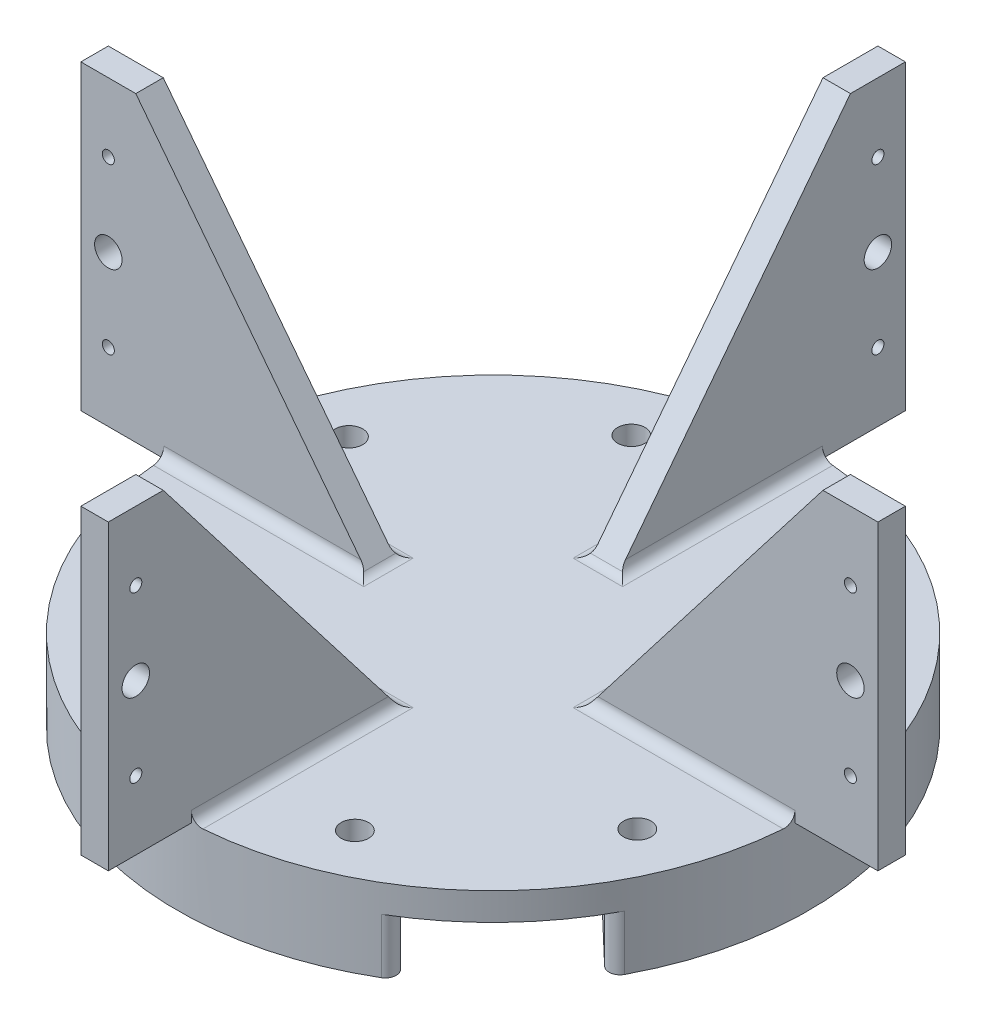
from build123d import *

# Parameters (mm, degrees)
SKETCH1_R           = 73.025
BOSS_EXTRUDE1_DEPTH = 19.05
CUT_EXTRUDE1_DEPTH  = 12.7
SKETCH3_R           = 3.175
CUT_EXTRUDE2_DEPTH  = 106.015254844
SKETCH6_R           = 1.397
SKETCH6_R_2         = 3.175
BOSS_EXTRUDE2_DEPTH = 3.175
FILLET1_R           = 7.62
FILLET2_R           = 2.54
CIRPATTERN1_COUNT   = 4
FILLET3_R           = 2.54


with BuildPart() as part:
    # Sketch1 → Boss-Extrude1 (new body)
    with BuildSketch(Plane(origin=(0, 0, 0), x_dir=(1, 0, 0), z_dir=(0, 1, 0))):
        Circle(SKETCH1_R)
    extrude(amount=-BOSS_EXTRUDE1_DEPTH)

    # Sketch2 → Cut-Extrude1 (cut)
    with BuildSketch(Plane.XZ.offset(19.05)):
        Polygon((47.265185668, 68.19146719), (-59.263487878, -33.567189015), (-36.236205762, -57.673893158), (70.292467784, 44.084763047), align=None)
    extrude(amount=-CUT_EXTRUDE1_DEPTH, mode=Mode.SUBTRACT)

    # Sketch3 → Cut-Extrude2 (cut, through all)
    with BuildSketch(Plane(origin=(0, 0, 0), x_dir=(1, 0, 0), z_dir=(0, 1, 0))):
        with Locations((-55.932366027, 22.598142748)):
            Circle(SKETCH3_R)
        with Locations((-23.570855326, 55.529455285)):
            Circle(SKETCH3_R)
        with Locations((22.598142748, 55.932366027)):
            Circle(SKETCH3_R)
        with Locations((55.529455285, 23.570855326)):
            Circle(SKETCH3_R)
        with Locations((55.932366027, -22.598142748)):
            Circle(SKETCH3_R)
        with Locations((23.570855326, -55.529455285)):
            Circle(SKETCH3_R)
        with Locations((-22.598142748, -55.932366027)):
            Circle(SKETCH3_R)
        with Locations((-55.529455285, -23.570855326)):
            Circle(SKETCH3_R)
    extrude(amount=-CUT_EXTRUDE2_DEPTH, mode=Mode.SUBTRACT)

    # Sketch6 → Boss-Extrude2 (add, symmetric)
    with BuildSketch(Plane.XY):
        Polygon((-25.460668916, 0), (-92.135668916, 0), (-92.135668916, 69.85), (-79.435668916, 69.85), align=None)
        with Locations((-85.785668916, 53.975)):
            Circle(SKETCH6_R, mode=Mode.SUBTRACT)
        with Locations((-85.785668916, 34.925)):
            Circle(SKETCH6_R_2, mode=Mode.SUBTRACT)
        with Locations((-85.785668916, 15.875)):
            Circle(SKETCH6_R, mode=Mode.SUBTRACT)
    boss_extrude2 = extrude(amount=BOSS_EXTRUDE2_DEPTH, both=True)

    # Fillet1
    fillet1_edges = [part.edges().sort_by_distance(p)[0] for p in [
        (-36.236205762, -12.7, -57.673893158),
        (-59.263487878, -12.7, -33.567189015),
    ]]
    fillet(fillet1_edges, radius=FILLET1_R)

    # Fillet2
    fillet2_edges = [part.edges().sort_by_distance(p)[0] for p in [
        (62.928056064, -12.7, 37.05010641),
        (39.902927025, -12.7, 61.158867222),
    ]]
    fillet(fillet2_edges, radius=FILLET2_R)

    # CirPattern1: Boss-Extrude2 ×4 about axis
    cirpattern1_axis = Axis((0, -19.05, 0), (0, 1, 0))
    for i in range(1, CIRPATTERN1_COUNT):
        add(boss_extrude2.rotate(cirpattern1_axis, i * 360 / CIRPATTERN1_COUNT))

    # Fillet3
    fillet3_edges = [part.edges().sort_by_distance(p)[0] for p in [
        (-49.208307264, 0, 3.175),
        (-25.460668916, 0, 0),
        (-49.208307264, 0, -3.175),
        (3.175, 0, 49.208307264),
        (0, 0, 25.460668916),
        (-3.175, 0, 49.208307264),
        (49.208307264, 0, 3.175),
        (25.460668916, 0, 0),
        (49.208307264, 0, -3.175),
        (3.175, 0, -49.208307264),
        (0, 0, -25.460668916),
        (-3.175, 0, -49.208307264),
    ]]
    fillet(fillet3_edges, radius=FILLET3_R)


solid = part.part
